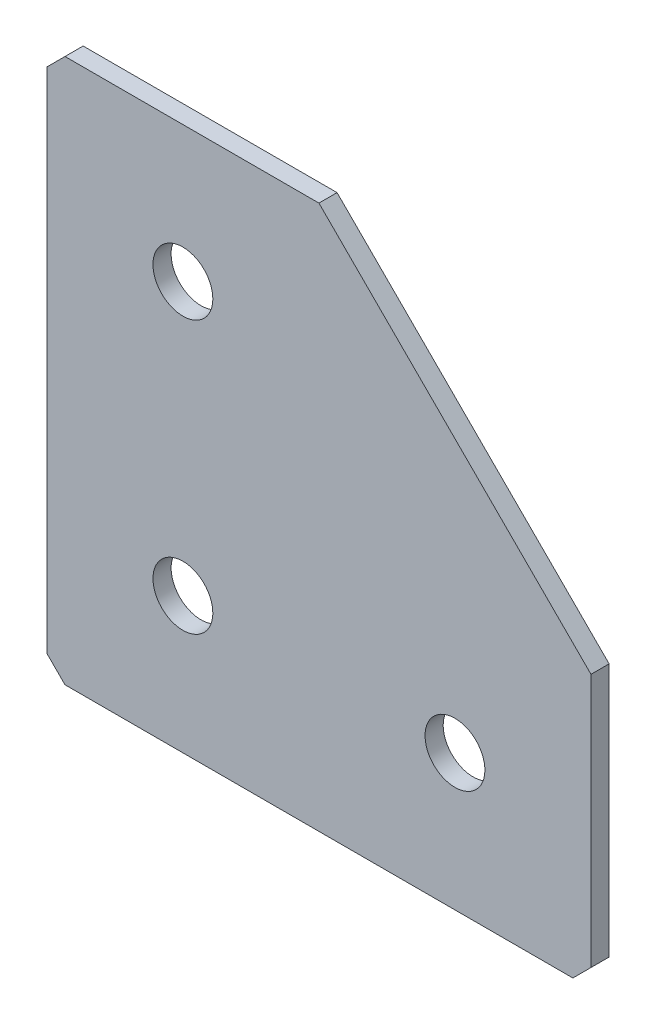
from build123d import *

# Parameters (mm, degrees)
EXTRUDE_1_DEPTH   = 2
HOLE_WIZARD_M61_D = 6.6
CHAMFER_1_SIZE    = 2


with BuildPart() as part:
    # Эскиз1 → Бобышка-Вытянуть1 (new body)
    with BuildSketch(Plane(origin=(0, 0, 0), x_dir=(1, 0, 0), z_dir=(0, 0, -1))):
        Polygon((0, 0), (0, 60), (60, 60), (60, 30), (30, 0), align=None)
    extrude(amount=EXTRUDE_1_DEPTH)

    # Отверстие с зазором M61 (through all)
    with Locations(Plane(origin=(0, 0, -2), x_dir=(1, 0, 0), z_dir=(0, 0, -1))):
        with Locations((15, 45), (15, 15), (45, 45)):
            Hole(HOLE_WIZARD_M61_D / 2)

    # Фаска1
    chamfer_1_edges = [part.edges().sort_by_distance(p)[0] for p in [
        (0, 0, -1),
        (0, -60, -1),
        (60, -60, -1),
    ]]
    chamfer(chamfer_1_edges, length=CHAMFER_1_SIZE)


solid = part.part
